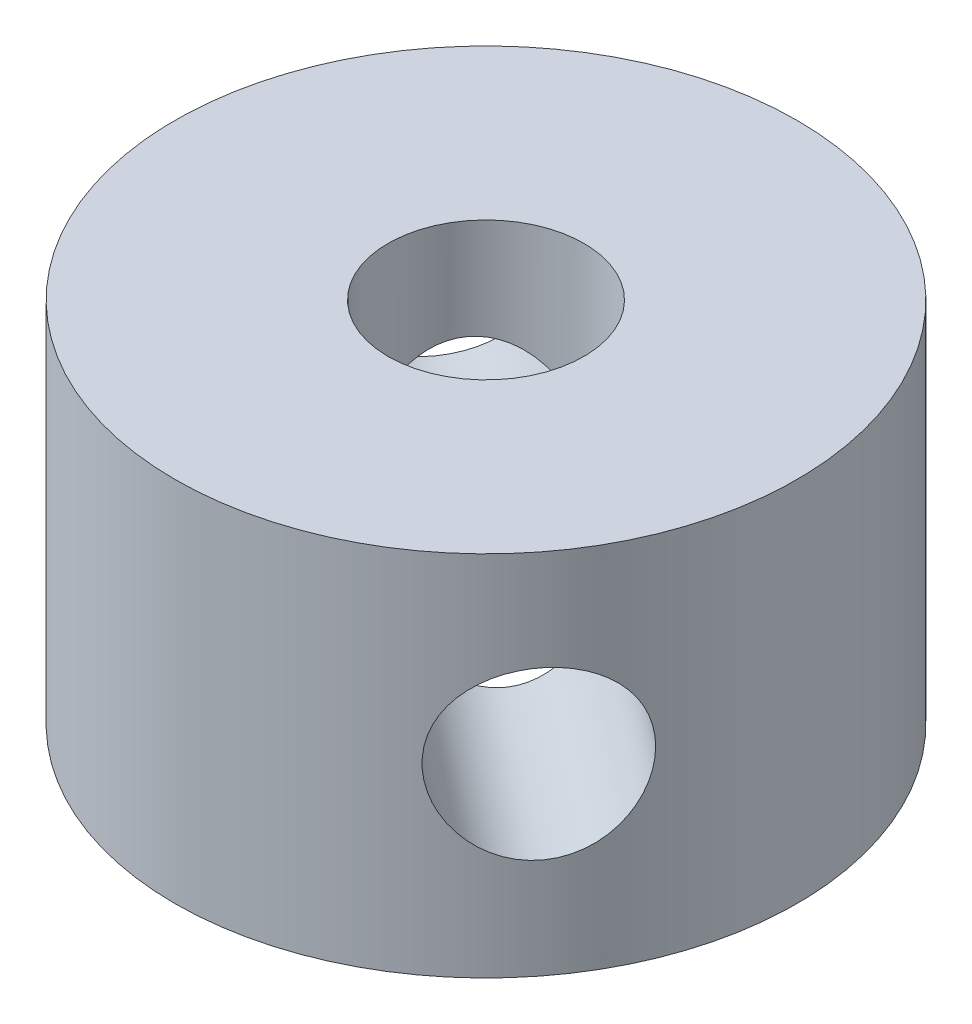
from build123d import *

# Parameters (mm, degrees)
SKETCH1_R                      = 12.7
SKETCH1_R_2                    = 4
BOSS_EXTRUDE1_DEPTH            = 15
F_6_8_6_8_DIAMETER_HOLE1_D     = 6.8
F_6_8_6_8_DIAMETER_HOLE1_DEPTH = 300
F_6_8_6_8_DIAMETER_HOLE1_TIP   = 2.042926105


with BuildPart() as part:
    # Sketch1 → Boss-Extrude1 (new body)
    with BuildSketch(Plane(origin=(0, 0, 0), x_dir=(1, 0, 0), z_dir=(0, 1, 0))):
        Circle(SKETCH1_R)
        Circle(SKETCH1_R_2, mode=Mode.SUBTRACT)
    extrude(amount=BOSS_EXTRUDE1_DEPTH)

    # Ø6.8 (6.8) Diameter Hole1
    with Locations(Plane(origin=(10.029659004, 7.5, 7.790759929), x_dir=(-0.613445664, 0, 0.789736929), z_dir=(0.789736929, 0, 0.613445664))):
        with Locations((0, 0)):
            Hole(F_6_8_6_8_DIAMETER_HOLE1_D / 2, depth=F_6_8_6_8_DIAMETER_HOLE1_DEPTH)
            with Locations((0, 0, -(F_6_8_6_8_DIAMETER_HOLE1_DEPTH + F_6_8_6_8_DIAMETER_HOLE1_TIP / 2))):  # 118° drill point
                Cone(0, F_6_8_6_8_DIAMETER_HOLE1_D / 2, F_6_8_6_8_DIAMETER_HOLE1_TIP, mode=Mode.SUBTRACT)


solid = part.part
